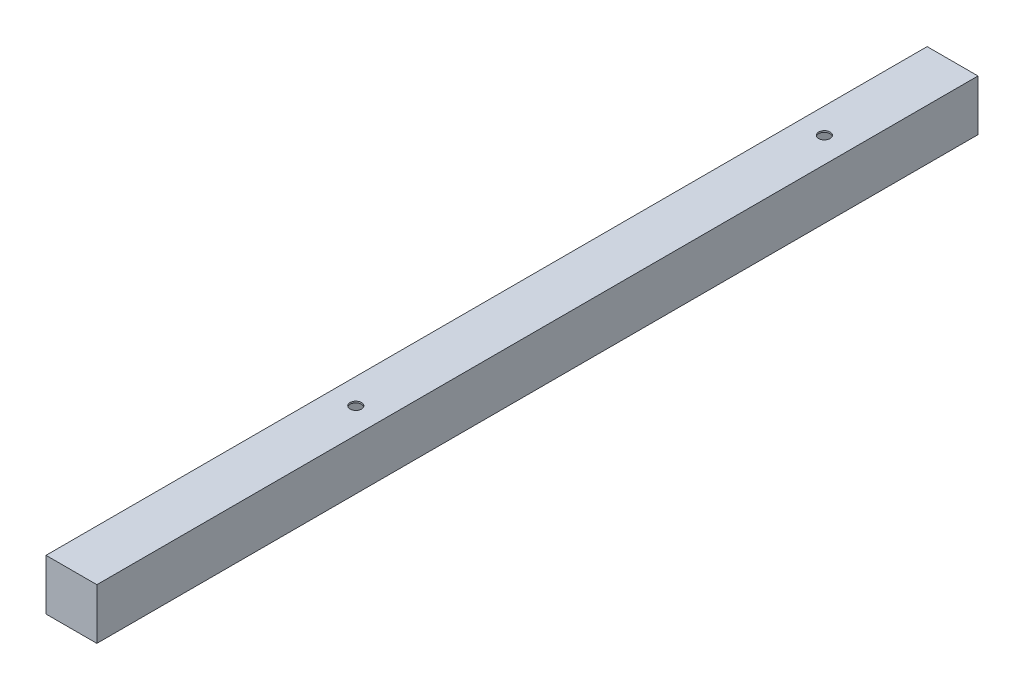
from build123d import *

# Parameters (mm, degrees)
CROQUIS1_W              = 63.5
CROQUIS1_H              = 63.5
CROQUIS1_W_2            = 59.7
CROQUIS1_H_2            = 59.7
SALIENTE_EXTRUIR1_DEPTH = 1100
CROQUIS2_W              = 59.7
CROQUIS2_H              = 59.7
SALIENTE_EXTRUIR2_DEPTH = 2
CROQUIS3_W              = 59.7
CROQUIS3_H              = 59.7
SALIENTE_EXTRUIR3_DEPTH = 2
CROQUIS4_R              = 7.14375
CORTAR_EXTRUIR1_DEPTH   = 120


with BuildPart() as part:
    # Croquis1 → Saliente-Extruir1 (new body)
    with BuildSketch(Plane.XY):
        with Locations((31.75, -31.75)):
            Rectangle(CROQUIS1_W, CROQUIS1_H)
        with Locations((31.75, -31.75)):
            Rectangle(CROQUIS1_W_2, CROQUIS1_H_2, mode=Mode.SUBTRACT)
    extrude(amount=SALIENTE_EXTRUIR1_DEPTH)

    # Croquis2 → Saliente-Extruir2 (add)
    with BuildSketch(Plane.XY.offset(1100)):
        with Locations((31.75, -31.75)):
            Rectangle(CROQUIS2_W, CROQUIS2_H)
    extrude(amount=-SALIENTE_EXTRUIR2_DEPTH)

    # Croquis3 → Saliente-Extruir3 (add)
    with BuildSketch(Plane(origin=(0, 0, 0), x_dir=(-1, 0, 0), z_dir=(0, 0, -1))):
        with Locations((-31.75, -31.75)):
            Rectangle(CROQUIS3_W, CROQUIS3_H)
    extrude(amount=-SALIENTE_EXTRUIR3_DEPTH)

    # Croquis4 → Cortar-Extruir1 (cut)
    with BuildSketch(Plane(origin=(0, 0, 0), x_dir=(1, 0, 0), z_dir=(0, 1, 0))):
        with Locations((31.75, -160)):
            Circle(CROQUIS4_R)
        with Locations((31.75, -745)):
            Circle(CROQUIS4_R)
    extrude(amount=-CORTAR_EXTRUIR1_DEPTH, mode=Mode.SUBTRACT)


solid = part.part
